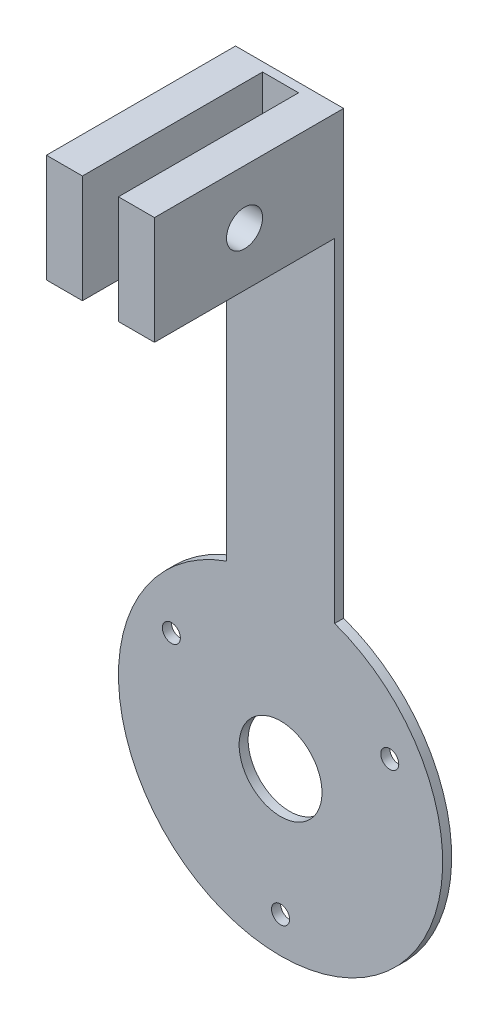
from build123d import *

# Parameters (mm, degrees)
SKETCH1_R           = 14.605
BOSS_EXTRUDE1_DEPTH = 3.175
SKETCH2_R           = 3.175
CUT_EXTRUDE1_DEPTH  = 228.649935482
SKETCH2_3_W         = 12.7
SKETCH2_3_H         = 38.1
BOSS_EXTRUDE2_DEPTH = 63.5
SKETCH3_R           = 6.35
CUT_EXTRUDE2_DEPTH  = 245.969305475
CUT_EXTRUDE3_DEPTH  = 237.318984637


with BuildPart() as part:
    # Sketch1 → Boss-Extrude1 (new body)
    with BuildSketch(Plane.XY):
        Polygon((-19.05, 88.9), (-88.9, 88.9), (-88.9, -88.9), (88.9, -88.9), (88.9, 88.9), (19.05, 88.9), (19.05, 209.55), (-19.05, 209.55), align=None)
        Circle(SKETCH1_R, mode=Mode.SUBTRACT)
    extrude(amount=BOSS_EXTRUDE1_DEPTH)

    # Sketch2 → Cut-Extrude1 (cut, through all)
    with BuildSketch(Plane.XY.offset(3.175)):
        with Locations((-38.494829198, 22.225)):
            Circle(SKETCH2_R)
        with Locations((0, -44.45)):
            Circle(SKETCH2_R)
        with Locations((38.494829198, 22.225)):
            Circle(SKETCH2_R)
    extrude(amount=-CUT_EXTRUDE1_DEPTH, mode=Mode.SUBTRACT)

    # Sketch2_3 → Boss-Extrude2 (add)
    with BuildSketch(Plane.XY.offset(3.175)):
        with Locations((-12.7, 190.5)):
            Rectangle(SKETCH2_3_W, SKETCH2_3_H)
        with Locations((12.7, 190.5)):
            Rectangle(SKETCH2_3_W, SKETCH2_3_H)
    extrude(amount=BOSS_EXTRUDE2_DEPTH)

    # Sketch3 → Cut-Extrude2 (cut, through all)
    with BuildSketch(Plane.ZY.offset(19.05)):
        with Locations((34.925, 190.5)):
            Circle(SKETCH3_R)
    extrude(amount=-CUT_EXTRUDE2_DEPTH, mode=Mode.SUBTRACT)

    # Sketch4 → Cut-Extrude3 (cut, through all)
    with BuildSketch(Plane.XY.offset(3.175)):
        with BuildLine():
            Line((-19.05, 53.881536726), (-19.05, 88.9))
            Line((-19.05, 88.9), (-88.9, 88.9))
            Line((-88.9, 88.9), (-88.9, -88.9))
            Line((-88.9, -88.9), (88.9, -88.9))
            Line((88.9, -88.9), (88.9, 88.9))
            Line((88.9, 88.9), (19.05, 88.9))
            Line((19.05, 88.9), (19.05, 53.881536726))
            ThreePointArc((19.05, 53.881536726), (46.6627796, 32.995567884), (57.15, 0))
            ThreePointArc((57.15, 0), (-32.995567884, -46.6627796), (-19.05, 53.881536726))
        make_face()
    extrude(amount=-CUT_EXTRUDE3_DEPTH, mode=Mode.SUBTRACT)


solid = part.part
